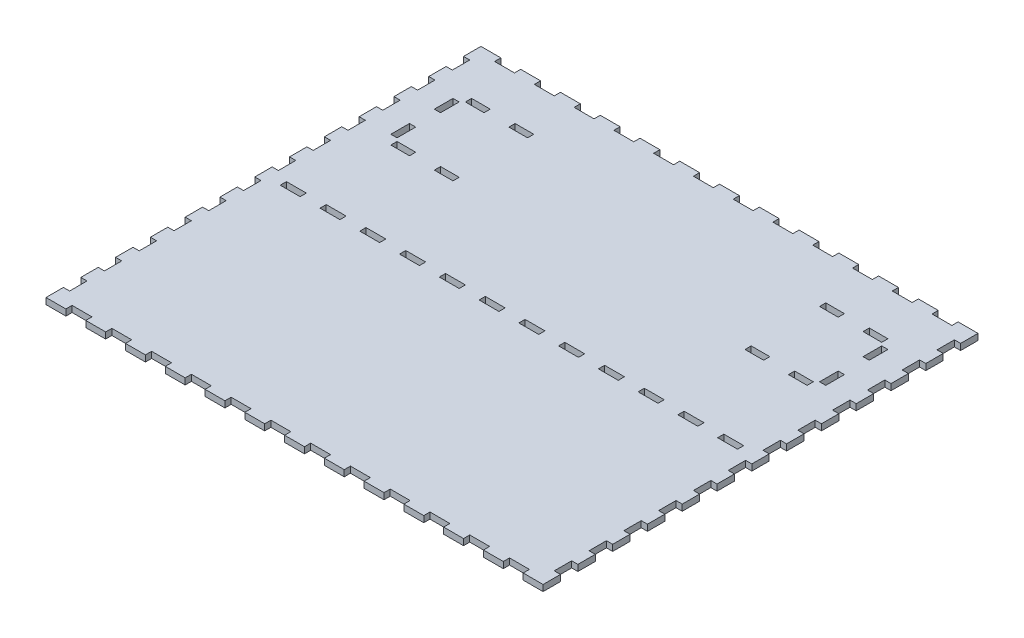
from build123d import *

# Parameters (mm, degrees)
ESQUISSE1_W                = 400
ESQUISSE1_H                = 350
BOSS_EXTRU_1_DEPTH         = 5
ESQUISSE2_W                = 16
ESQUISSE2_H                = 5
ENL_V_MAT_EXTRU_1_DEPTH    = 5
R_P_TITION_LIN_AIRE1_COUNT = 12
R_P_TITION_LIN_AIRE1_PITCH = 32
ESQUISSE3_W                = 5
ESQUISSE3_H                = 14
ENL_V_MAT_EXTRU_2_DEPTH    = 5
R_P_TITION_LIN_AIRE2_COUNT = 12
R_P_TITION_LIN_AIRE2_PITCH = 28
SYM_TRIE1_COPY_1_SKETCH_W  = 16
SYM_TRIE1_COPY_1_SKETCH_H  = 5
SYM_TRIE1_COPY_1_DEPTH     = 5
SYM_TRIE1_COPY_2_SKETCH_W  = 16
SYM_TRIE1_COPY_2_SKETCH_H  = 5
SYM_TRIE1_COPY_2_DEPTH     = 5
SYM_TRIE1_COPY_3_SKETCH_W  = 16
SYM_TRIE1_COPY_3_SKETCH_H  = 5
SYM_TRIE1_COPY_3_DEPTH     = 5
SYM_TRIE1_COPY_4_SKETCH_W  = 16
SYM_TRIE1_COPY_4_SKETCH_H  = 5
SYM_TRIE1_COPY_4_DEPTH     = 5
SYM_TRIE1_COPY_5_SKETCH_W  = 16
SYM_TRIE1_COPY_5_SKETCH_H  = 5
SYM_TRIE1_COPY_5_DEPTH     = 5
SYM_TRIE1_COPY_6_SKETCH_W  = 16
SYM_TRIE1_COPY_6_SKETCH_H  = 5
SYM_TRIE1_COPY_6_DEPTH     = 5
SYM_TRIE1_COPY_7_SKETCH_W  = 16
SYM_TRIE1_COPY_7_SKETCH_H  = 5
SYM_TRIE1_COPY_7_DEPTH     = 5
SYM_TRIE1_COPY_8_SKETCH_W  = 16
SYM_TRIE1_COPY_8_SKETCH_H  = 5
SYM_TRIE1_COPY_8_DEPTH     = 5
SYM_TRIE1_COPY_9_SKETCH_W  = 16
SYM_TRIE1_COPY_9_SKETCH_H  = 5
SYM_TRIE1_COPY_9_DEPTH     = 5
SYM_TRIE1_COPY_10_SKETCH_W = 16
SYM_TRIE1_COPY_10_SKETCH_H = 5
SYM_TRIE1_COPY_10_DEPTH    = 5
SYM_TRIE1_COPY_11_SKETCH_W = 16
SYM_TRIE1_COPY_11_SKETCH_H = 5
SYM_TRIE1_COPY_11_DEPTH    = 5
SYM_TRIE2_COPY_1_SKETCH_W  = 5
SYM_TRIE2_COPY_1_SKETCH_H  = 14
SYM_TRIE2_COPY_1_DEPTH     = 5
SYM_TRIE2_COPY_2_SKETCH_W  = 5
SYM_TRIE2_COPY_2_SKETCH_H  = 14
SYM_TRIE2_COPY_2_DEPTH     = 5
SYM_TRIE2_COPY_3_SKETCH_W  = 5
SYM_TRIE2_COPY_3_SKETCH_H  = 14
SYM_TRIE2_COPY_3_DEPTH     = 5
SYM_TRIE2_COPY_4_SKETCH_W  = 5
SYM_TRIE2_COPY_4_SKETCH_H  = 14
SYM_TRIE2_COPY_4_DEPTH     = 5
SYM_TRIE2_COPY_5_SKETCH_W  = 5
SYM_TRIE2_COPY_5_SKETCH_H  = 14
SYM_TRIE2_COPY_5_DEPTH     = 5
SYM_TRIE2_COPY_6_SKETCH_W  = 5
SYM_TRIE2_COPY_6_SKETCH_H  = 14
SYM_TRIE2_COPY_6_DEPTH     = 5
SYM_TRIE2_COPY_7_SKETCH_W  = 5
SYM_TRIE2_COPY_7_SKETCH_H  = 14
SYM_TRIE2_COPY_7_DEPTH     = 5
SYM_TRIE2_COPY_8_SKETCH_W  = 5
SYM_TRIE2_COPY_8_SKETCH_H  = 14
SYM_TRIE2_COPY_8_DEPTH     = 5
SYM_TRIE2_COPY_9_SKETCH_W  = 5
SYM_TRIE2_COPY_9_SKETCH_H  = 14
SYM_TRIE2_COPY_9_DEPTH     = 5
SYM_TRIE2_COPY_10_SKETCH_W = 5
SYM_TRIE2_COPY_10_SKETCH_H = 14
SYM_TRIE2_COPY_10_DEPTH    = 5
SYM_TRIE2_COPY_11_SKETCH_W = 5
SYM_TRIE2_COPY_11_SKETCH_H = 14
SYM_TRIE2_COPY_11_DEPTH    = 5
ESQUISSE4_W                = 15
ESQUISSE4_H                = 5
ESQUISSE4_W_2              = 5
ESQUISSE4_H_2              = 15
ENL_V_MAT_EXTRU_3_DEPTH    = 5
ESQUISSE5_W                = 16
ESQUISSE5_H                = 5
ENL_V_MAT_EXTRU_4_DEPTH    = 10
R_P_TITION_LIN_AIRE3_COUNT = 12
R_P_TITION_LIN_AIRE3_PITCH = 32


with BuildPart() as part:
    # Esquisse1 → Boss.-Extru.1 (new body)
    with BuildSketch(Plane(origin=(0, 0, 0), x_dir=(1, 0, 0), z_dir=(0, 1, 0))):
        with Locations((200, -175)):
            Rectangle(ESQUISSE1_W, ESQUISSE1_H)
    extrude(amount=BOSS_EXTRU_1_DEPTH)

    # Esquisse2 → Enlèv. mat.-Extru.1 (cut)
    with BuildSketch(Plane(origin=(0, 5, 0), x_dir=(1, 0, 0), z_dir=(0, 1, 0))):
        with Locations((24, -2.5)):
            Rectangle(ESQUISSE2_W, ESQUISSE2_H)
    enl_v_mat_extru_1 = extrude(amount=-ENL_V_MAT_EXTRU_1_DEPTH, mode=Mode.SUBTRACT)

    # Répétition linéaire1: Enlèv. mat.-Extru.1 ×12
    with Locations(*[(i * R_P_TITION_LIN_AIRE1_PITCH, 0, 0) for i in range(1, R_P_TITION_LIN_AIRE1_COUNT)]):
        add(enl_v_mat_extru_1, mode=Mode.SUBTRACT)

    # Esquisse3 → Enlèv. mat.-Extru.2 (cut)
    with BuildSketch(Plane(origin=(0, 5, 0), x_dir=(1, 0, 0), z_dir=(0, 1, 0))):
        with Locations((2.5, -21)):
            Rectangle(ESQUISSE3_W, ESQUISSE3_H)
    enl_v_mat_extru_2 = extrude(amount=-ENL_V_MAT_EXTRU_2_DEPTH, mode=Mode.SUBTRACT)

    # Répétition linéaire2: Enlèv. mat.-Extru.2 ×12
    with Locations(*[(0, 0, i * R_P_TITION_LIN_AIRE2_PITCH) for i in range(1, R_P_TITION_LIN_AIRE2_COUNT)]):
        add(enl_v_mat_extru_2, mode=Mode.SUBTRACT)

    # Symétrie1: Enlèv. mat.-Extru.1 across plane
    add(enl_v_mat_extru_1.mirror(Plane(origin=(0, 0, 175), x_dir=(1, 0, 0), z_dir=(0, 0, -1))), mode=Mode.SUBTRACT)

    # Symétrie1 copy 1 sketch → Symétrie1 copy 1 (cut)
    with BuildSketch(Plane(origin=(32, 5, 350), x_dir=(1, 0, 0), z_dir=(0, 1, 0))):
        with Locations((24, 2.5)):
            Rectangle(SYM_TRIE1_COPY_1_SKETCH_W, SYM_TRIE1_COPY_1_SKETCH_H)
    extrude(amount=-SYM_TRIE1_COPY_1_DEPTH, mode=Mode.SUBTRACT)

    # Symétrie1 copy 2 sketch → Symétrie1 copy 2 (cut)
    with BuildSketch(Plane(origin=(64, 5, 350), x_dir=(1, 0, 0), z_dir=(0, 1, 0))):
        with Locations((24, 2.5)):
            Rectangle(SYM_TRIE1_COPY_2_SKETCH_W, SYM_TRIE1_COPY_2_SKETCH_H)
    extrude(amount=-SYM_TRIE1_COPY_2_DEPTH, mode=Mode.SUBTRACT)

    # Symétrie1 copy 3 sketch → Symétrie1 copy 3 (cut)
    with BuildSketch(Plane(origin=(96, 5, 350), x_dir=(1, 0, 0), z_dir=(0, 1, 0))):
        with Locations((24, 2.5)):
            Rectangle(SYM_TRIE1_COPY_3_SKETCH_W, SYM_TRIE1_COPY_3_SKETCH_H)
    extrude(amount=-SYM_TRIE1_COPY_3_DEPTH, mode=Mode.SUBTRACT)

    # Symétrie1 copy 4 sketch → Symétrie1 copy 4 (cut)
    with BuildSketch(Plane(origin=(128, 5, 350), x_dir=(1, 0, 0), z_dir=(0, 1, 0))):
        with Locations((24, 2.5)):
            Rectangle(SYM_TRIE1_COPY_4_SKETCH_W, SYM_TRIE1_COPY_4_SKETCH_H)
    extrude(amount=-SYM_TRIE1_COPY_4_DEPTH, mode=Mode.SUBTRACT)

    # Symétrie1 copy 5 sketch → Symétrie1 copy 5 (cut)
    with BuildSketch(Plane(origin=(160, 5, 350), x_dir=(1, 0, 0), z_dir=(0, 1, 0))):
        with Locations((24, 2.5)):
            Rectangle(SYM_TRIE1_COPY_5_SKETCH_W, SYM_TRIE1_COPY_5_SKETCH_H)
    extrude(amount=-SYM_TRIE1_COPY_5_DEPTH, mode=Mode.SUBTRACT)

    # Symétrie1 copy 6 sketch → Symétrie1 copy 6 (cut)
    with BuildSketch(Plane(origin=(192, 5, 350), x_dir=(1, 0, 0), z_dir=(0, 1, 0))):
        with Locations((24, 2.5)):
            Rectangle(SYM_TRIE1_COPY_6_SKETCH_W, SYM_TRIE1_COPY_6_SKETCH_H)
    extrude(amount=-SYM_TRIE1_COPY_6_DEPTH, mode=Mode.SUBTRACT)

    # Symétrie1 copy 7 sketch → Symétrie1 copy 7 (cut)
    with BuildSketch(Plane(origin=(224, 5, 350), x_dir=(1, 0, 0), z_dir=(0, 1, 0))):
        with Locations((24, 2.5)):
            Rectangle(SYM_TRIE1_COPY_7_SKETCH_W, SYM_TRIE1_COPY_7_SKETCH_H)
    extrude(amount=-SYM_TRIE1_COPY_7_DEPTH, mode=Mode.SUBTRACT)

    # Symétrie1 copy 8 sketch → Symétrie1 copy 8 (cut)
    with BuildSketch(Plane(origin=(256, 5, 350), x_dir=(1, 0, 0), z_dir=(0, 1, 0))):
        with Locations((24, 2.5)):
            Rectangle(SYM_TRIE1_COPY_8_SKETCH_W, SYM_TRIE1_COPY_8_SKETCH_H)
    extrude(amount=-SYM_TRIE1_COPY_8_DEPTH, mode=Mode.SUBTRACT)

    # Symétrie1 copy 9 sketch → Symétrie1 copy 9 (cut)
    with BuildSketch(Plane(origin=(288, 5, 350), x_dir=(1, 0, 0), z_dir=(0, 1, 0))):
        with Locations((24, 2.5)):
            Rectangle(SYM_TRIE1_COPY_9_SKETCH_W, SYM_TRIE1_COPY_9_SKETCH_H)
    extrude(amount=-SYM_TRIE1_COPY_9_DEPTH, mode=Mode.SUBTRACT)

    # Symétrie1 copy 10 sketch → Symétrie1 copy 10 (cut)
    with BuildSketch(Plane(origin=(320, 5, 350), x_dir=(1, 0, 0), z_dir=(0, 1, 0))):
        with Locations((24, 2.5)):
            Rectangle(SYM_TRIE1_COPY_10_SKETCH_W, SYM_TRIE1_COPY_10_SKETCH_H)
    extrude(amount=-SYM_TRIE1_COPY_10_DEPTH, mode=Mode.SUBTRACT)

    # Symétrie1 copy 11 sketch → Symétrie1 copy 11 (cut)
    with BuildSketch(Plane(origin=(352, 5, 350), x_dir=(1, 0, 0), z_dir=(0, 1, 0))):
        with Locations((24, 2.5)):
            Rectangle(SYM_TRIE1_COPY_11_SKETCH_W, SYM_TRIE1_COPY_11_SKETCH_H)
    extrude(amount=-SYM_TRIE1_COPY_11_DEPTH, mode=Mode.SUBTRACT)

    # Symétrie2: Enlèv. mat.-Extru.2 across plane
    add(enl_v_mat_extru_2.mirror(Plane(origin=(200, 0, 0), x_dir=(0, 0, 1), z_dir=(1, 0, 0))), mode=Mode.SUBTRACT)

    # Symétrie2 copy 1 sketch → Symétrie2 copy 1 (cut)
    with BuildSketch(Plane(origin=(400, 5, 28), x_dir=(-1, 0, 0), z_dir=(0, 1, 0))):
        with Locations((2.5, 21)):
            Rectangle(SYM_TRIE2_COPY_1_SKETCH_W, SYM_TRIE2_COPY_1_SKETCH_H)
    extrude(amount=-SYM_TRIE2_COPY_1_DEPTH, mode=Mode.SUBTRACT)

    # Symétrie2 copy 2 sketch → Symétrie2 copy 2 (cut)
    with BuildSketch(Plane(origin=(400, 5, 56), x_dir=(-1, 0, 0), z_dir=(0, 1, 0))):
        with Locations((2.5, 21)):
            Rectangle(SYM_TRIE2_COPY_2_SKETCH_W, SYM_TRIE2_COPY_2_SKETCH_H)
    extrude(amount=-SYM_TRIE2_COPY_2_DEPTH, mode=Mode.SUBTRACT)

    # Symétrie2 copy 3 sketch → Symétrie2 copy 3 (cut)
    with BuildSketch(Plane(origin=(400, 5, 84), x_dir=(-1, 0, 0), z_dir=(0, 1, 0))):
        with Locations((2.5, 21)):
            Rectangle(SYM_TRIE2_COPY_3_SKETCH_W, SYM_TRIE2_COPY_3_SKETCH_H)
    extrude(amount=-SYM_TRIE2_COPY_3_DEPTH, mode=Mode.SUBTRACT)

    # Symétrie2 copy 4 sketch → Symétrie2 copy 4 (cut)
    with BuildSketch(Plane(origin=(400, 5, 112), x_dir=(-1, 0, 0), z_dir=(0, 1, 0))):
        with Locations((2.5, 21)):
            Rectangle(SYM_TRIE2_COPY_4_SKETCH_W, SYM_TRIE2_COPY_4_SKETCH_H)
    extrude(amount=-SYM_TRIE2_COPY_4_DEPTH, mode=Mode.SUBTRACT)

    # Symétrie2 copy 5 sketch → Symétrie2 copy 5 (cut)
    with BuildSketch(Plane(origin=(400, 5, 140), x_dir=(-1, 0, 0), z_dir=(0, 1, 0))):
        with Locations((2.5, 21)):
            Rectangle(SYM_TRIE2_COPY_5_SKETCH_W, SYM_TRIE2_COPY_5_SKETCH_H)
    extrude(amount=-SYM_TRIE2_COPY_5_DEPTH, mode=Mode.SUBTRACT)

    # Symétrie2 copy 6 sketch → Symétrie2 copy 6 (cut)
    with BuildSketch(Plane(origin=(400, 5, 168), x_dir=(-1, 0, 0), z_dir=(0, 1, 0))):
        with Locations((2.5, 21)):
            Rectangle(SYM_TRIE2_COPY_6_SKETCH_W, SYM_TRIE2_COPY_6_SKETCH_H)
    extrude(amount=-SYM_TRIE2_COPY_6_DEPTH, mode=Mode.SUBTRACT)

    # Symétrie2 copy 7 sketch → Symétrie2 copy 7 (cut)
    with BuildSketch(Plane(origin=(400, 5, 196), x_dir=(-1, 0, 0), z_dir=(0, 1, 0))):
        with Locations((2.5, 21)):
            Rectangle(SYM_TRIE2_COPY_7_SKETCH_W, SYM_TRIE2_COPY_7_SKETCH_H)
    extrude(amount=-SYM_TRIE2_COPY_7_DEPTH, mode=Mode.SUBTRACT)

    # Symétrie2 copy 8 sketch → Symétrie2 copy 8 (cut)
    with BuildSketch(Plane(origin=(400, 5, 224), x_dir=(-1, 0, 0), z_dir=(0, 1, 0))):
        with Locations((2.5, 21)):
            Rectangle(SYM_TRIE2_COPY_8_SKETCH_W, SYM_TRIE2_COPY_8_SKETCH_H)
    extrude(amount=-SYM_TRIE2_COPY_8_DEPTH, mode=Mode.SUBTRACT)

    # Symétrie2 copy 9 sketch → Symétrie2 copy 9 (cut)
    with BuildSketch(Plane(origin=(400, 5, 252), x_dir=(-1, 0, 0), z_dir=(0, 1, 0))):
        with Locations((2.5, 21)):
            Rectangle(SYM_TRIE2_COPY_9_SKETCH_W, SYM_TRIE2_COPY_9_SKETCH_H)
    extrude(amount=-SYM_TRIE2_COPY_9_DEPTH, mode=Mode.SUBTRACT)

    # Symétrie2 copy 10 sketch → Symétrie2 copy 10 (cut)
    with BuildSketch(Plane(origin=(400, 5, 280), x_dir=(-1, 0, 0), z_dir=(0, 1, 0))):
        with Locations((2.5, 21)):
            Rectangle(SYM_TRIE2_COPY_10_SKETCH_W, SYM_TRIE2_COPY_10_SKETCH_H)
    extrude(amount=-SYM_TRIE2_COPY_10_DEPTH, mode=Mode.SUBTRACT)

    # Symétrie2 copy 11 sketch → Symétrie2 copy 11 (cut)
    with BuildSketch(Plane(origin=(400, 5, 308), x_dir=(-1, 0, 0), z_dir=(0, 1, 0))):
        with Locations((2.5, 21)):
            Rectangle(SYM_TRIE2_COPY_11_SKETCH_W, SYM_TRIE2_COPY_11_SKETCH_H)
    extrude(amount=-SYM_TRIE2_COPY_11_DEPTH, mode=Mode.SUBTRACT)

    # Esquisse4 → Enlèv. mat.-Extru.3 (cut)
    with BuildSketch(Plane(origin=(0, 5, 0), x_dir=(1, 0, 0), z_dir=(0, 1, 0))):
        with Locations((40, -42.5)):
            Rectangle(ESQUISSE4_W, ESQUISSE4_H)
        with Locations((75, -42.5)):
            Rectangle(ESQUISSE4_W, ESQUISSE4_H)
        with Locations((40, -102.5)):
            Rectangle(ESQUISSE4_W, ESQUISSE4_H)
        with Locations((75, -102.5)):
            Rectangle(ESQUISSE4_W, ESQUISSE4_H)
        with Locations((27.5, -55)):
            Rectangle(ESQUISSE4_W_2, ESQUISSE4_H_2)
        with Locations((27.5, -90)):
            Rectangle(ESQUISSE4_W_2, ESQUISSE4_H_2)
    enl_v_mat_extru_3 = extrude(amount=-ENL_V_MAT_EXTRU_3_DEPTH, mode=Mode.SUBTRACT)

    # Symétrie3: Enlèv. mat.-Extru.3 across plane
    add(enl_v_mat_extru_3.mirror(Plane(origin=(200, 0, 0), x_dir=(0, 0, 1), z_dir=(1, 0, 0))), mode=Mode.SUBTRACT)

    # Esquisse5 → Enlèv. mat.-Extru.4 (cut)
    with BuildSketch(Plane(origin=(0, 5, 0), x_dir=(1, 0, 0), z_dir=(0, 1, 0))):
        with Locations((24, -175)):
            Rectangle(ESQUISSE5_W, ESQUISSE5_H)
    enl_v_mat_extru_4 = extrude(amount=-ENL_V_MAT_EXTRU_4_DEPTH, mode=Mode.SUBTRACT)

    # Répétition linéaire3: Enlèv. mat.-Extru.4 ×12
    with Locations(*[(i * R_P_TITION_LIN_AIRE3_PITCH, 0, 0) for i in range(1, R_P_TITION_LIN_AIRE3_COUNT)]):
        add(enl_v_mat_extru_4, mode=Mode.SUBTRACT)


solid = part.part
